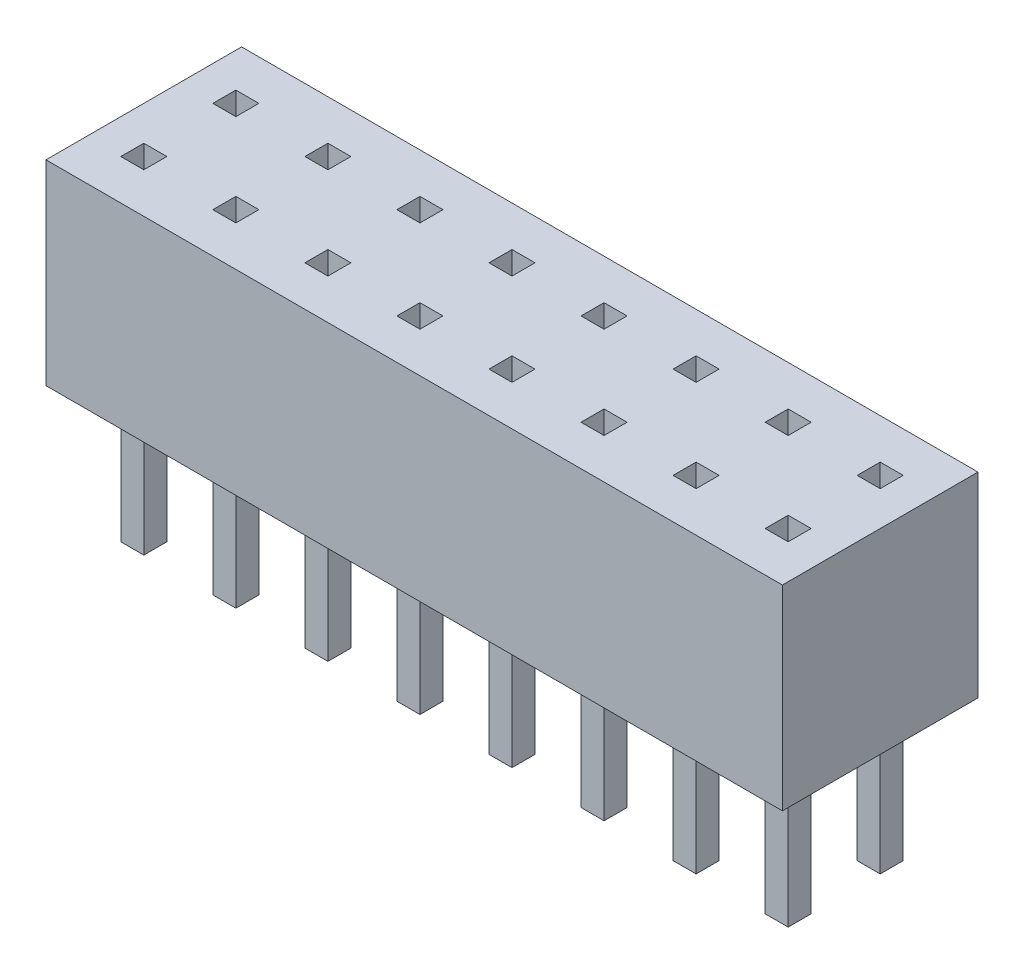
from build123d import *

# Parameters (mm, degrees)
SKETCH1_W           = 16
SKETCH1_H           = 4.25
BOSS_EXTRUDE1_DEPTH = 4.25
SKETCH3_W           = 0.5
SKETCH3_H           = 0.5
BOSS_EXTRUDE2_DEPTH = 3
SKETCH4_W           = 0.5
SKETCH4_H           = 0.5
CUT_EXTRUDE1_DEPTH  = 4


with BuildPart() as part:
    # Sketch1 → Boss-Extrude1 (new body)
    with BuildSketch(Plane(origin=(0, 0, 0), x_dir=(1, 0, 0), z_dir=(0, 1, 0))):
        with Locations((8, -2.125)):
            Rectangle(SKETCH1_W, SKETCH1_H)
    extrude(amount=BOSS_EXTRUDE1_DEPTH)

    # Sketch3 → Boss-Extrude2 (add)
    with BuildSketch(Plane.XZ):
        with Locations((3, 1.125)):
            Rectangle(SKETCH3_W, SKETCH3_H)
        with Locations((1, 1.125)):
            Rectangle(SKETCH3_W, SKETCH3_H)
        with Locations((5, 1.125)):
            Rectangle(SKETCH3_W, SKETCH3_H)
        with Locations((7, 1.125)):
            Rectangle(SKETCH3_W, SKETCH3_H)
        with Locations((9, 1.125)):
            Rectangle(SKETCH3_W, SKETCH3_H)
        with Locations((11, 1.125)):
            Rectangle(SKETCH3_W, SKETCH3_H)
        with Locations((13, 1.125)):
            Rectangle(SKETCH3_W, SKETCH3_H)
        with Locations((15, 1.125)):
            Rectangle(SKETCH3_W, SKETCH3_H)
        with Locations((1, 3.125)):
            Rectangle(SKETCH3_W, SKETCH3_H)
        with Locations((3, 3.125)):
            Rectangle(SKETCH3_W, SKETCH3_H)
        with Locations((5, 3.125)):
            Rectangle(SKETCH3_W, SKETCH3_H)
        with Locations((7, 3.125)):
            Rectangle(SKETCH3_W, SKETCH3_H)
        with Locations((9, 3.125)):
            Rectangle(SKETCH3_W, SKETCH3_H)
        with Locations((11, 3.125)):
            Rectangle(SKETCH3_W, SKETCH3_H)
        with Locations((13, 3.125)):
            Rectangle(SKETCH3_W, SKETCH3_H)
        with Locations((15, 3.125)):
            Rectangle(SKETCH3_W, SKETCH3_H)
    extrude(amount=BOSS_EXTRUDE2_DEPTH)

    # Sketch4 → Cut-Extrude1 (cut)
    with BuildSketch(Plane(origin=(0, 4.25, 0), x_dir=(-1, 0, 0), z_dir=(0, 1, 0))):
        with Locations((-15, 1.125)):
            Rectangle(SKETCH4_W, SKETCH4_H)
        with Locations((-13, 1.125)):
            Rectangle(SKETCH4_W, SKETCH4_H)
        with Locations((-11, 1.125)):
            Rectangle(SKETCH4_W, SKETCH4_H)
        with Locations((-9, 1.125)):
            Rectangle(SKETCH4_W, SKETCH4_H)
        with Locations((-7, 1.125)):
            Rectangle(SKETCH4_W, SKETCH4_H)
        with Locations((-5, 1.125)):
            Rectangle(SKETCH4_W, SKETCH4_H)
        with Locations((-3, 1.125)):
            Rectangle(SKETCH4_W, SKETCH4_H)
        with Locations((-1, 1.125)):
            Rectangle(SKETCH4_W, SKETCH4_H)
        with Locations((-15, 3.125)):
            Rectangle(SKETCH4_W, SKETCH4_H)
        with Locations((-13, 3.125)):
            Rectangle(SKETCH4_W, SKETCH4_H)
        with Locations((-11, 3.125)):
            Rectangle(SKETCH4_W, SKETCH4_H)
        with Locations((-9, 3.125)):
            Rectangle(SKETCH4_W, SKETCH4_H)
        with Locations((-7, 3.125)):
            Rectangle(SKETCH4_W, SKETCH4_H)
        with Locations((-5, 3.125)):
            Rectangle(SKETCH4_W, SKETCH4_H)
        with Locations((-3, 3.125)):
            Rectangle(SKETCH4_W, SKETCH4_H)
        with Locations((-1, 3.125)):
            Rectangle(SKETCH4_W, SKETCH4_H)
    extrude(amount=-CUT_EXTRUDE1_DEPTH, mode=Mode.SUBTRACT)


solid = part.part
